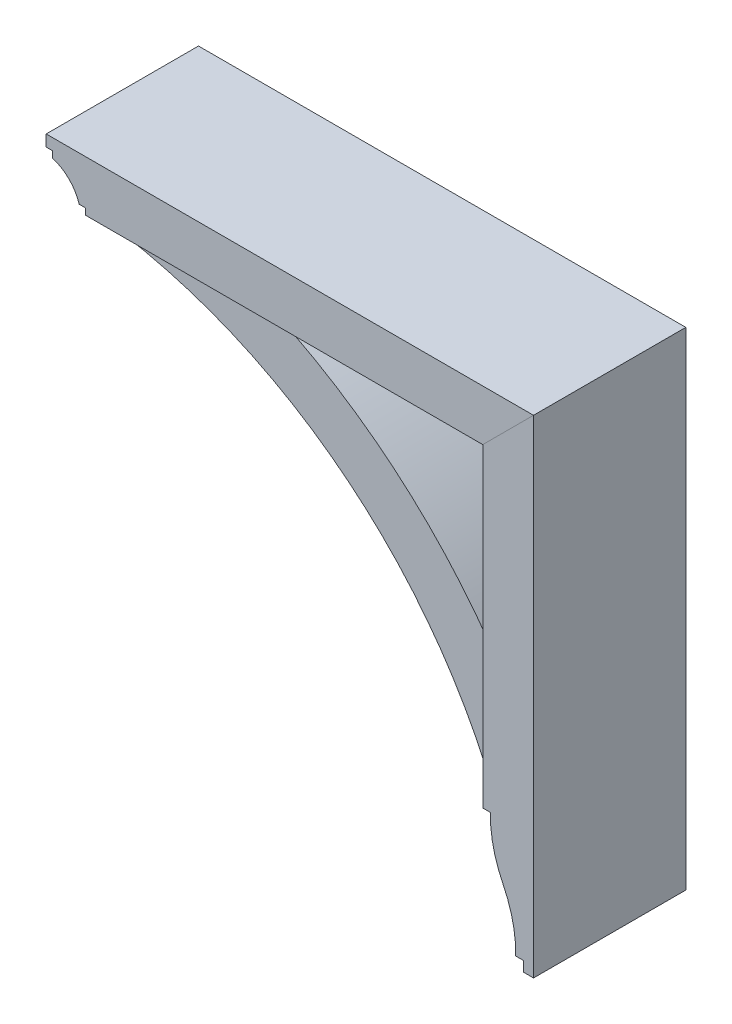
from build123d import *

# Parameters (mm, degrees)
BOSS_EXTRUDE1_DEPTH = 95.25
BOSS_EXTRUDE2_DEPTH = 69.85
BOSS_EXTRUDE3_DEPTH = 95.25


with BuildPart() as part:
    # Sketch1 → Boss-Extrude1 (new body, symmetric)
    with BuildSketch(Plane.XY):
        with BuildLine():
            Line((-303.981276984, 251.46), (-303.981276984, 259.3975))
            Line((-303.981276984, 259.3975), (-311.918776984, 259.3975))
            Line((-311.918776984, 259.3975), (-311.918776984, 273.685))
            Line((-311.918776984, 273.685), (297.681223016, 273.685))
            Line((297.681223016, 273.685), (234.181223016, 210.185))
            Line((234.181223016, 210.185), (-262.706276984, 210.185))
            Line((-262.706276984, 210.185), (-262.706276984, 218.1225))
            Line((-262.706276984, 218.1225), (-270.643776984, 218.1225))
            ThreePointArc((-270.643776984, 218.1225), (-283.204800802, 238.898976183), (-303.981276984, 251.46))
        make_face()
    extrude(amount=BOSS_EXTRUDE1_DEPTH, both=True)


with BuildPart() as body_2:
    # Sketch1_3 → Boss-Extrude2 (new body, symmetric)
    with BuildSketch(Plane.XY):
        with BuildLine():
            ThreePointArc((234.181223016, -51.7525), (97.353674253, 103.618191485), (-80.143776984, 210.185))
            Line((-80.143776984, 210.185), (-240.481276984, 210.185))
            Line((-240.481276984, 210.185), (-240.481276984, 187.96))
            ThreePointArc((-240.481276984, 187.96), (29.333912258, 69.812205382), (211.956223016, -161.29))
            Line((211.956223016, -161.29), (234.181223016, -161.29))
            Line((234.181223016, -161.29), (234.181223016, -51.7525))
        make_face()
    extrude(amount=BOSS_EXTRUDE2_DEPTH, both=True)


with BuildPart() as body_3:
    # Sketch1_4 → Boss-Extrude3 (new body, symmetric)
    with BuildSketch(Plane.XY):
        with BuildLine():
            Line((297.681223016, -335.915), (297.681223016, 273.685))
            Line((297.681223016, 273.685), (234.181223016, 210.185))
            Line((234.181223016, 210.185), (234.181223016, -183.515))
            Line((234.181223016, -183.515), (243.706223016, -183.515))
            ThreePointArc((243.706223016, -183.515), (247.436467782, -219.396194371), (259.581223016, -253.365))
            ThreePointArc((259.581223016, -253.365), (271.725978249, -287.333805629), (275.456223016, -323.215))
            Line((275.456223016, -323.215), (284.981223016, -323.215))
            Line((284.981223016, -323.215), (284.981223016, -335.915))
            Line((284.981223016, -335.915), (297.681223016, -335.915))
        make_face()
    extrude(amount=BOSS_EXTRUDE3_DEPTH, both=True)


solid = Compound([part.part, body_2.part, body_3.part])
